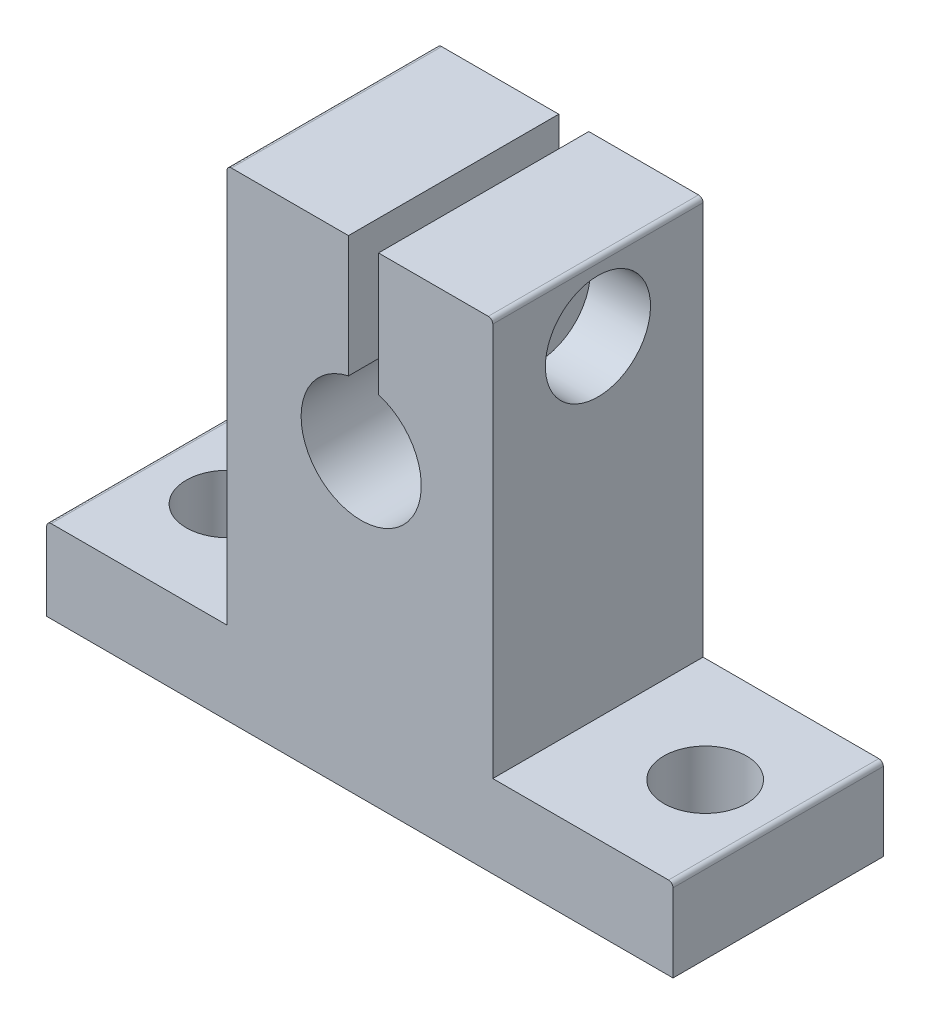
from build123d import *

# Parameters (mm, degrees)
SKETCH1_R           = 4
BOSS_EXTRUDE1_DEPTH = 14
SKETCH2_R           = 2.75
CUT_EXTRUDE1_DEPTH  = 6
SKETCH3_W           = 2
SKETCH3_H           = 11.620769134
CUT_EXTRUDE2_DEPTH  = 14
SKETCH4_R           = 2
CUT_EXTRUDE3_DEPTH  = 9
SKETCH5_R           = 3.5
CUT_EXTRUDE4_DEPTH  = 4
SKETCH6_R           = 1.85
CUT_EXTRUDE5_DEPTH  = 9
FILLET1_R           = 0.3


with BuildPart() as part:
    # Sketch1 → Boss-Extrude1 (new body)
    with BuildSketch(Plane.XY):
        Polygon((-20.938905162, 0.786403392), (-8.938905162, 0.786403392), (-8.938905162, 27.286403392), (8.761094838, 27.286403392), (8.761094838, 0.786403392), (20.761094838, 0.786403392), (20.761094838, -4.713596608), (-20.938905162, -4.713596608), align=None)
        with Locations((0, 15.286403392)):
            Circle(SKETCH1_R, mode=Mode.SUBTRACT)
    extrude(amount=BOSS_EXTRUDE1_DEPTH)

    # Sketch2 → Cut-Extrude1 (cut)
    with BuildSketch(Plane(origin=(0, 0.786403392, 0), x_dir=(1, 0, 0), z_dir=(0, 1, 0))):
        with Locations((-15.9, -7)):
            Circle(SKETCH2_R)
        with Locations((15.9, -7)):
            Circle(SKETCH2_R)
    extrude(amount=-CUT_EXTRUDE1_DEPTH, mode=Mode.SUBTRACT)

    # Sketch3 → Cut-Extrude2 (cut)
    with BuildSketch(Plane.XY.offset(14)):
        with Locations((0.152630001, 23.872597077)):
            Rectangle(SKETCH3_W, SKETCH3_H)
    extrude(amount=-CUT_EXTRUDE2_DEPTH, mode=Mode.SUBTRACT)

    # Sketch4 → Cut-Extrude3 (cut)
    with BuildSketch(Plane(origin=(8.761094838, 0, 0), x_dir=(0, 0, -1), z_dir=(1, 0, 0))):
        with Locations((-7, 22.786403392)):
            Circle(SKETCH4_R)
    extrude(amount=-CUT_EXTRUDE3_DEPTH, mode=Mode.SUBTRACT)

    # Sketch5 → Cut-Extrude4 (cut)
    with BuildSketch(Plane(origin=(8.761094838, 0, 0), x_dir=(0, 0, -1), z_dir=(1, 0, 0))):
        with Locations((-7, 22.786403392)):
            Circle(SKETCH5_R)
    extrude(amount=-CUT_EXTRUDE4_DEPTH, mode=Mode.SUBTRACT)

    # Sketch6 → Cut-Extrude5 (cut)
    with BuildSketch(Plane.ZY.offset(8.938905162)):
        with Locations((7, 22.786403392)):
            Circle(SKETCH6_R)
    extrude(amount=-CUT_EXTRUDE5_DEPTH, mode=Mode.SUBTRACT)

    # Fillet1
    fillet1_edges = [part.edges().sort_by_distance(p)[0] for p in [
        (-20.938905162, 0.786403392, 7),
        (-8.938905162, 27.286403392, 7),
        (8.761094838, 27.286403392, 7),
        (20.761094838, 0.786403392, 7),
    ]]
    fillet(fillet1_edges, radius=FILLET1_R)


solid = part.part
